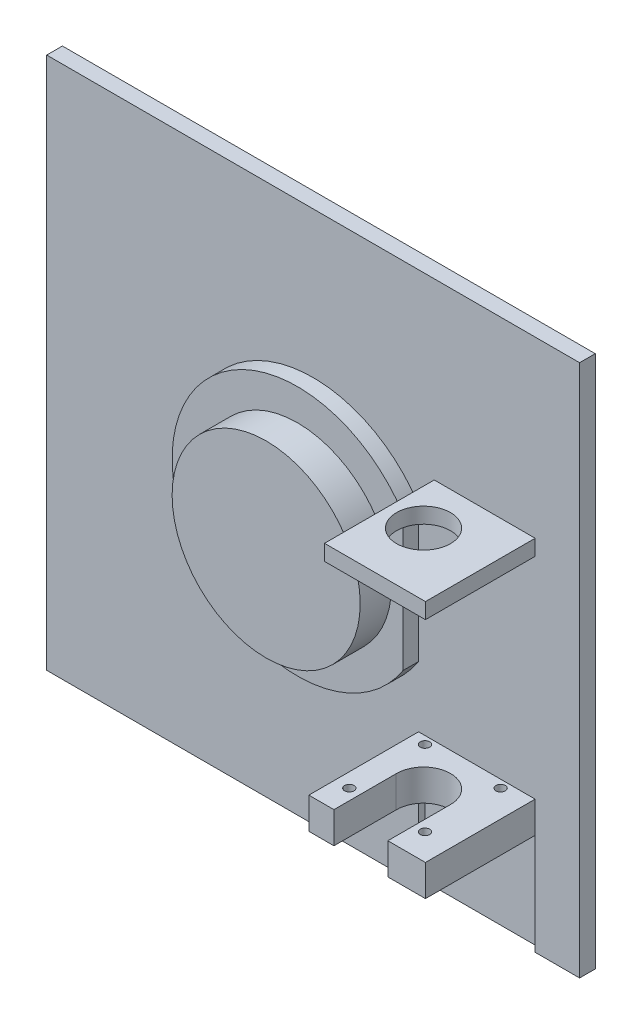
from build123d import *

# Parameters (mm, degrees)
SKETCH1_W           = 215.9
SKETCH1_H           = 215.9
BOSS_EXTRUDE1_DEPTH = 12.7
BOSS_EXTRUDE2_DEPTH = 38.1
SKETCH4_W           = 47.244
SKETCH4_H           = 41.06164
CUT_EXTRUDE1_DEPTH  = 8.89
SKETCH6_W           = 47.244
SKETCH6_H           = 6.35
BOSS_EXTRUDE3_DEPTH = 38.1
SKETCH5_R           = 10.922
CUT_EXTRUDE2_DEPTH  = 175.83836
CUT_EXTRUDE4_DEPTH  = 38.1
SKETCH9_W           = 47.244
SKETCH9_H           = 85.1916
CUT_EXTRUDE5_DEPTH  = 6.35
SKETCH12_R          = 38.1
BOSS_EXTRUDE4_DEPTH = 12.7
SKETCH14_W          = 38.1
SKETCH14_H          = 6.35
CUT_EXTRUDE7_DEPTH  = 6.35
SKETCH10_R          = 1.905
CUT_EXTRUDE9_DEPTH  = 12.7
CUT_EXTRUDE10_DEPTH = 6.35


with BuildPart() as part:
    # Sketch1 → Boss-Extrude1 (new body)
    with BuildSketch(Plane.XY):
        with Locations((107.95, 107.95)):
            Rectangle(SKETCH1_W, SKETCH1_H)
    extrude(amount=BOSS_EXTRUDE1_DEPTH)

    # Sketch2 → Boss-Extrude2 (add)
    with BuildSketch(Plane.XY.offset(12.7)):
        Polygon((174.2694, 41.06164), (197.8914, 41.06164), (197.8914, 53.76164), (150.6474, 53.76164), (150.6474, 41.06164), align=None)
    extrude(amount=BOSS_EXTRUDE2_DEPTH)

    # Sketch4 → Cut-Extrude1 (cut)
    with BuildSketch(Plane.XY.offset(12.7)):
        with Locations((174.2694, 20.53082)):
            Rectangle(SKETCH4_W, SKETCH4_H)
    extrude(amount=-CUT_EXTRUDE1_DEPTH, mode=Mode.SUBTRACT)

    # Sketch6 → Boss-Extrude3 (add)
    with BuildSketch(Plane.XY.offset(12.7)):
        with Locations((174.2694, 142.12824)):
            Rectangle(SKETCH6_W, SKETCH6_H)
    extrude(amount=BOSS_EXTRUDE3_DEPTH)

    # Sketch5 → Cut-Extrude2 (cut, through all)
    with BuildSketch(Plane.XZ.offset(-41.06164)):
        with Locations((171.730776396, 25.411523701)):
            Circle(SKETCH5_R)
    extrude(amount=-CUT_EXTRUDE2_DEPTH, mode=Mode.SUBTRACT)

    # Sketch8 → Cut-Extrude4 (cut)
    with BuildSketch(Plane.XZ.offset(-41.06164)):
        with BuildLine():
            Line((160.812004434, 25.146), (160.812004434, 50.8))
            Line((160.812004434, 50.8), (182.649548358, 50.8))
            Line((182.649548358, 50.8), (182.649548358, 25.146))
            ThreePointArc((182.649548358, 25.146), (171.730776396, 36.064771962), (160.812004434, 25.146))
        make_face()
    extrude(amount=-CUT_EXTRUDE4_DEPTH, mode=Mode.SUBTRACT)

    # Sketch9 → Cut-Extrude5 (cut)
    with BuildSketch(Plane.XY.offset(12.7)):
        with Locations((174.2694, 96.35744)):
            Rectangle(SKETCH9_W, SKETCH9_H)
    extrude(amount=-CUT_EXTRUDE5_DEPTH, mode=Mode.SUBTRACT)

    # Sketch12 → Boss-Extrude4 (add)
    with BuildSketch(Plane.XY.offset(12.7)):
        with Locations((107.95, 105.927514247)):
            Circle(SKETCH12_R)
    extrude(amount=BOSS_EXTRUDE4_DEPTH)

    # Sketch14 → Cut-Extrude7 (cut)
    with BuildSketch(Plane.ZY.offset(-150.6474)):
        with Locations((31.75, 142.12824)):
            Rectangle(SKETCH14_W, SKETCH14_H)
    extrude(amount=-CUT_EXTRUDE7_DEPTH, mode=Mode.SUBTRACT)

    # Sketch10 → Cut-Extrude9 (cut)
    with BuildSketch(Plane.XZ.offset(-41.06164)):
        with Locations((187.059676396, 9.498423701)):
            Circle(SKETCH10_R)
        with Locations((156.401876396, 9.498423701)):
            Circle(SKETCH10_R)
        with Locations((156.401876396, 40.156223701)):
            Circle(SKETCH10_R)
        with Locations((187.059676396, 40.156223701)):
            Circle(SKETCH10_R)
    extrude(amount=-CUT_EXTRUDE9_DEPTH, mode=Mode.SUBTRACT)

    # Sketch15 → Cut-Extrude10 (cut)
    with BuildSketch(Plane.XY.offset(12.7)):
        with BuildLine():
            Line((197.8914, 145.30324), (197.8914, 0))
            Line((197.8914, 0), (215.9, 0))
            Line((215.9, 0), (215.9, 215.9))
            Line((215.9, 215.9), (0, 215.9))
            Line((0, 215.9), (0, 0))
            Line((0, 0), (150.6474, 0))
            Line((150.6474, 0), (150.6474, 78.403487774))
            ThreePointArc((150.6474, 78.403487774), (57.15, 105.927514247), (150.6474, 133.451540719))
            Line((150.6474, 133.451540719), (150.6474, 138.95324))
            Line((150.6474, 138.95324), (156.9974, 145.30324))
            Line((156.9974, 145.30324), (197.8914, 145.30324))
        make_face()
    extrude(amount=-CUT_EXTRUDE10_DEPTH, mode=Mode.SUBTRACT)


solid = part.part
